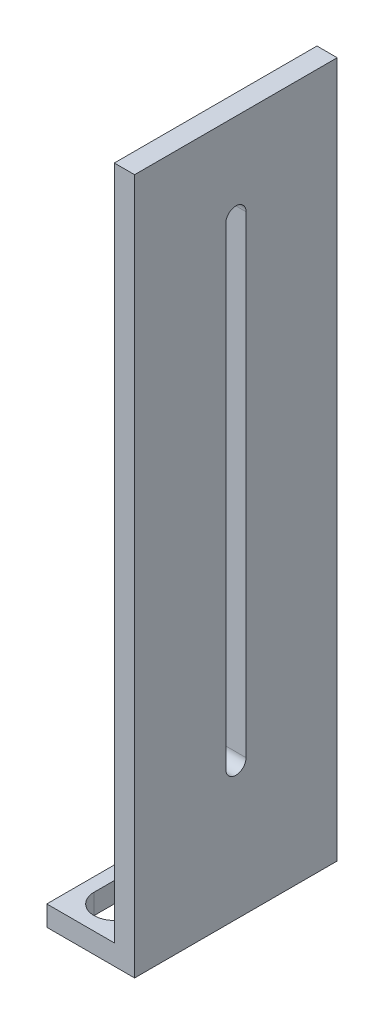
from build123d import *

# Parameters (mm, degrees)
SKETCH_5_W          = 10
SKETCH_5_H          = 30
EXTRUDE_5_DEPTH     = 3
SKETCH_6_W          = 30
SKETCH_6_H          = 100
SKETCH_6_H_2        = 3
EXTRUDE_6_DEPTH     = 3
CUT_EXTRUDE_2_DEPTH = 3


with BuildPart() as part:
    # 草图5 → 凸台-拉伸5 (new body)
    with BuildSketch(Plane(origin=(0, 0, 0), x_dir=(1, 0, 0), z_dir=(0, 1, 0))):
        with Locations((5, -15)):
            Rectangle(SKETCH_5_W, SKETCH_5_H)
        with BuildLine():
            Line((8, -5), (8, -25))
            ThreePointArc((8, -25), (5, -28), (2, -25))
            Line((2, -25), (2, -5))
            ThreePointArc((2, -5), (5, -2), (8, -5))
        make_face(mode=Mode.SUBTRACT)
    extrude(amount=EXTRUDE_5_DEPTH)

    # 草图6 → 凸台-拉伸6 (add)
    with BuildSketch(Plane(origin=(10, 0, 0), x_dir=(0, 0, -1), z_dir=(1, 0, 0))):
        with Locations((-15, 53)):
            Rectangle(SKETCH_6_W, SKETCH_6_H)
        with Locations((-15, 1.5)):
            Rectangle(SKETCH_6_W, SKETCH_6_H_2)
    extrude(amount=EXTRUDE_6_DEPTH)

    # 草图7 → 切除-拉伸2 (cut)
    with BuildSketch(Plane.ZY.offset(-10)):
        with BuildLine():
            Line((16.5, 90), (16.5, 20))
            ThreePointArc((16.5, 20), (15, 18.5), (13.5, 20))
            Line((13.5, 20), (13.5, 90))
            ThreePointArc((13.5, 90), (15, 91.5), (16.5, 90))
        make_face()
    extrude(amount=-CUT_EXTRUDE_2_DEPTH, mode=Mode.SUBTRACT)


solid = part.part
